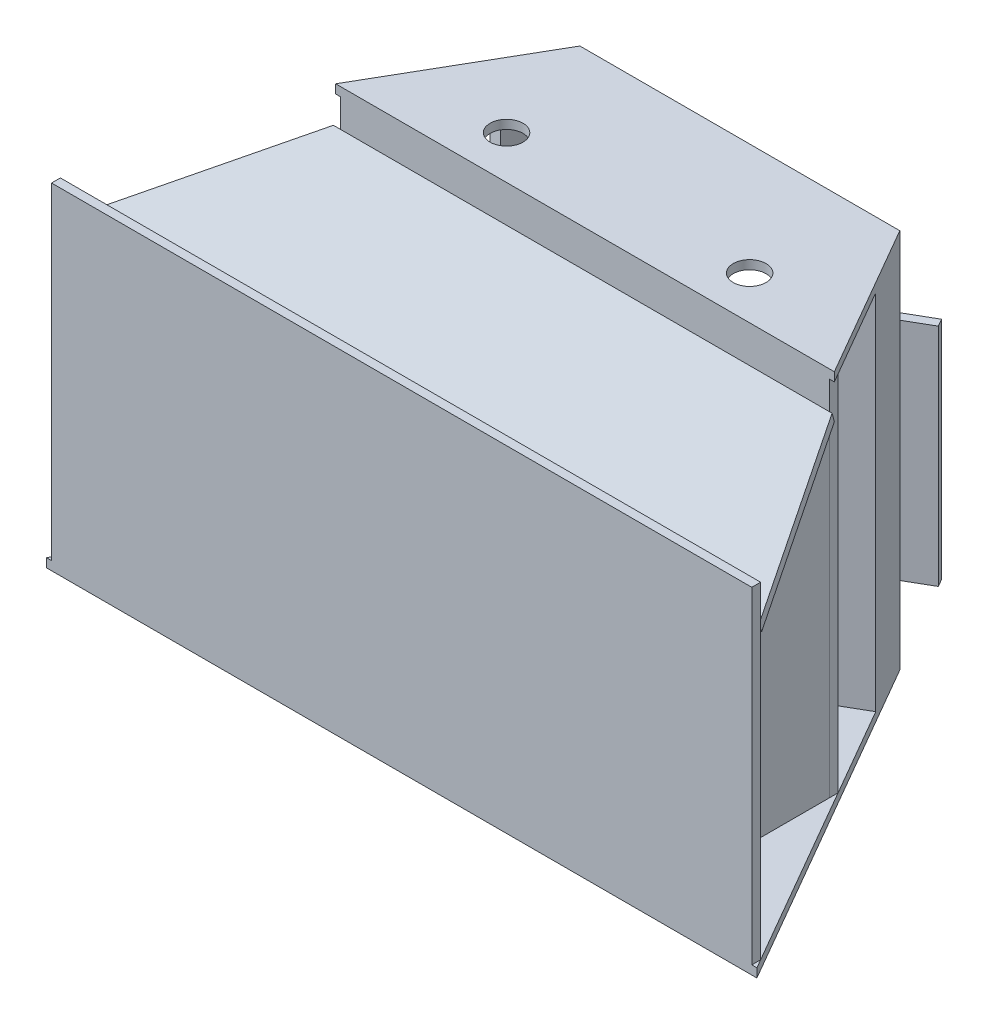
from build123d import *

# Parameters (mm, degrees)
BOSS_EXTRUDE1_DEPTH                     = 11.90625
SKETCH3_W                               = 946.658829024
SKETCH3_H                               = 11.90625
BOSS_EXTRUDE2_DEPTH                     = 442.11875
SKETCH4_W                               = 660.481708072
SKETCH4_H                               = 11.90625
BOSS_EXTRUDE3_DEPTH                     = 502.444211
BOSS_EXTRUDE4_DEPTH                     = 11.90625
CUT_EXTRUDE2_REACH                      = 516.35
SKETCH6_R                               = 22.225
BOSS_EXTRUDE5_DEPTH                     = 11.90625
BOSS_EXTRUDE8_DEPTH                     = 11.90625
SKETCH9_W                               = 457.2
SKETCH9_H                               = 88.9
BOSS_EXTRUDE9_DEPTH                     = 2.921
SKETCH10_W                              = 457.2
SKETCH10_H                              = 88.9
SKETCH10_R                              = 22.225
BOSS_EXTRUDE10_DEPTH                    = 88.9
F_5_16_0_3125_DIAMETER_HOLE1_AT_2_COUNT = 2
F_5_16_0_3125_DIAMETER_HOLE1_AT_2_PITCH = 328.618993764
BOSS_EXTRUDE11_DEPTH                    = 490.537961
SKETCH12_W                              = 76.2
SKETCH12_H                              = 304.8
BOSS_EXTRUDE12_DEPTH                    = 11.90625
SKETCH18_W                              = 38.1
SKETCH18_H                              = 88.9
BOSS_EXTRUDE15_DEPTH                    = 636.669208
BOSS_EXTRUDE15_2_DEPTH                  = 636.669208
BOSS_EXTRUDE15_3_DEPTH                  = 636.669208


with BuildPart() as part:
    # Sketch2 → Boss-Extrude1 (new body)
    with BuildSketch(Plane(origin=(0, 0, 0), x_dir=(1, 0, 0), z_dir=(0, 1, 0))):
        Polygon((-480.203491154, -831.736844651), (-216.238948081, -374.536844651), (216.238948081, -374.536844651), (480.203491154, -831.736844651), align=None)
    extrude(amount=BOSS_EXTRUDE1_DEPTH)

    # Sketch3 → Boss-Extrude2 (add)
    with BuildSketch(Plane(origin=(0, 11.90625, 0), x_dir=(1, 0, 0), z_dir=(0, 1, 0))):
        with Locations((0, -825.783719651)):
            Rectangle(SKETCH3_W, SKETCH3_H)
    extrude(amount=BOSS_EXTRUDE2_DEPTH)

    # Sketch4 → Boss-Extrude3 (add)
    with BuildSketch(Plane(origin=(0, 11.90625, 0), x_dir=(1, 0, 0), z_dir=(0, 1, 0))):
        with Locations((0, -577.947062925)):
            Rectangle(SKETCH4_W, SKETCH4_H)
    extrude(amount=BOSS_EXTRUDE3_DEPTH)

    # Sketch5 → Boss-Extrude4 (add)
    with BuildSketch(Plane(origin=(0, 514.35046101, 0), x_dir=(1, 0, 0), z_dir=(0, 1, 0))):
        Polygon((-337.114930678, -583.900187925), (-216.238948081, -374.536844651), (216.238948081, -374.536844651), (337.114930678, -583.900187925), align=None)
    extrude(amount=-BOSS_EXTRUDE4_DEPTH)

    # Sketch6 → Cut-Extrude2 (cut, up to next)
    with BuildSketch(Plane(origin=(0, 514.35046101, 0), x_dir=(1, 0, 0), z_dir=(0, 1, 0)), mode=Mode.PRIVATE) as cut_extrude2_sk1:
        with Locations((-164.309496882, -525.607187925)):
            Circle(SKETCH6_R)
    cut_extrude2_tool1 = extrude(cut_extrude2_sk1.sketch, amount=-CUT_EXTRUDE2_REACH, mode=Mode.PRIVATE) & part.part
    add(cut_extrude2_tool1.solids().sort_by_distance((-164.309497, 514.350461, 525.607188))[0], mode=Mode.SUBTRACT)
    # Sketch6 → Cut-Extrude2 (cut, up to next)
    with BuildSketch(Plane(origin=(0, 514.35046101, 0), x_dir=(1, 0, 0), z_dir=(0, 1, 0)), mode=Mode.PRIVATE) as cut_extrude2_sk2:
        with Locations((164.309496882, -525.607187925)):
            Circle(SKETCH6_R)
    cut_extrude2_tool2 = extrude(cut_extrude2_sk2.sketch, amount=-CUT_EXTRUDE2_REACH, mode=Mode.PRIVATE) & part.part
    add(cut_extrude2_tool2.solids().sort_by_distance((164.309497, 514.350461, 525.607188))[0], mode=Mode.SUBTRACT)

    # Sketch9 → Boss-Extrude9 (add)
    with BuildSketch(Plane(origin=(0, 11.90625, 0), x_dir=(1, 0, 0), z_dir=(0, 1, 0))):
        with Locations((0, -527.543937925)):
            Rectangle(SKETCH9_W, SKETCH9_H)
    extrude(amount=BOSS_EXTRUDE9_DEPTH)

    # Sketch10 → Boss-Extrude10 (add)
    with BuildSketch(Plane(origin=(0, 14.82725, 0), x_dir=(1, 0, 0), z_dir=(0, 1, 0))):
        with Locations((0, -527.543937925)):
            Rectangle(SKETCH10_W, SKETCH10_H)
        with Locations((-164.309496882, -525.607187925)):
            Circle(SKETCH10_R, mode=Mode.SUBTRACT)
        with Locations((164.309496882, -525.607187925)):
            Circle(SKETCH10_R, mode=Mode.SUBTRACT)
    extrude(amount=BOSS_EXTRUDE10_DEPTH)

    # Sketch15 → 5_16 _0.3125_ Diameter Hole1 (revolve, cut)
    with BuildSketch(Plane(origin=(164.309496882, 78.32725, 483.093937925), x_dir=(0, 1, 0), z_dir=(1, 0, 0))):
        Polygon((0, 0), (0, 103.190915582), (3.96875, 100.80625), (3.96875, 0), align=None)
    f_5_16_0_3125_diameter_hole1 = revolve(axis=Axis((164.309496882, 78.32725, 476.743937925), (0, 0, 1)), mode=Mode.SUBTRACT)

    # 5_16 _0.3125_ Diameter Hole1 at 2: 5_16 _0.3125_ Diameter Hole1 ×2
    with Locations(*[(-i * F_5_16_0_3125_DIAMETER_HOLE1_AT_2_PITCH, 0, 0) for i in range(1, F_5_16_0_3125_DIAMETER_HOLE1_AT_2_COUNT)]):
        add(f_5_16_0_3125_diameter_hole1, mode=Mode.SUBTRACT)

    # Sketch11 → Boss-Extrude11 (add)
    with BuildSketch(Plane(origin=(0, 11.90625, 0), x_dir=(1, 0, 0), z_dir=(0, 1, 0))):
        Polygon((216.238948081, -374.536844651), (260.688948081, -451.526503047), (227.693380197, -470.576503047), (183.243380197, -393.586844651), align=None)
        Polygon((-216.238948081, -374.536844651), (-260.688948081, -451.526503047), (-227.693380196, -470.576503047), (-183.243380196, -393.586844651), align=None)
    extrude(amount=BOSS_EXTRUDE11_DEPTH)

    # Sketch12 → Boss-Extrude12 (add)
    with BuildSketch(Plane(origin=(216.238948081, 0, 374.536844651), x_dir=(-0.866025404, 0, 0.5), z_dir=(-0.5, 0, -0.866025404))):
        with Locations((0, 257.175230505)):
            Rectangle(SKETCH12_W, SKETCH12_H)
    extrude(amount=BOSS_EXTRUDE12_DEPTH)


with BuildPart() as body_2:
    # Sketch7 → Boss-Extrude5 (new body)
    with BuildSketch(Plane(origin=(0, 571.258129571, 153.068154488), x_dir=(1, 0, 0), z_dir=(0, 0.965925826, 0.258819045))):
        Polygon((-471.550272559, -687.09300222), (-337.114930678, -446.030141975), (337.114930678, -446.030141975), (471.550272559, -687.09300222), align=None)
    extrude(amount=BOSS_EXTRUDE5_DEPTH)


with BuildPart() as body_3:
    # Sketch8 → Boss-Extrude8 (new body)
    with BuildSketch(Plane(origin=(330.240854036, 0, 0), x_dir=(0, 0, -1), z_dir=(1, 0, 0))):
        Polygon((-819.830594651, 11.90625), (-819.830594651, 392.599672186), (-583.900187925, 455.817034138), (-583.900187925, 11.90625), align=None)
    extrude(amount=-BOSS_EXTRUDE8_DEPTH)


with BuildPart() as body_4:
    # Mirror2: mirrored copy
    add(body_3.part.mirror(Plane(origin=(0, 0, 0), x_dir=(0, 0, 1), z_dir=(1, 0, 0))))


with BuildPart() as body_5:
    # Sketch18 → Boss-Extrude15 (new body)
    with BuildSketch(Plane(origin=(318.334604036, 0, 0), x_dir=(0, 0, -1), z_dir=(1, 0, 0))):
        with Locations((-602.950187925, 401.158169907)):
            Rectangle(SKETCH18_W, SKETCH18_H)
    extrude(amount=-BOSS_EXTRUDE15_DEPTH)


with BuildPart() as body_6:
    # Sketch18 → Boss-Extrude15 2 (new body)
    with BuildSketch(Plane(origin=(318.334604036, 0, 0), x_dir=(0, 0, -1), z_dir=(1, 0, 0))):
        with Locations((-800.780594651, 348.97537484)):
            Rectangle(SKETCH18_W, SKETCH18_H)
    extrude(amount=-BOSS_EXTRUDE15_2_DEPTH)


with BuildPart() as body_7:
    # Sketch18 → Boss-Extrude15 3 (new body)
    with BuildSketch(Plane(origin=(318.334604036, 0, 0), x_dir=(0, 0, -1), z_dir=(1, 0, 0))):
        with Locations((-800.780594651, 56.35625)):
            Rectangle(SKETCH18_W, SKETCH18_H)
    extrude(amount=-BOSS_EXTRUDE15_3_DEPTH)


solid = Compound([part.part, body_2.part, body_3.part, body_4.part, body_5.part, body_6.part, body_7.part])
